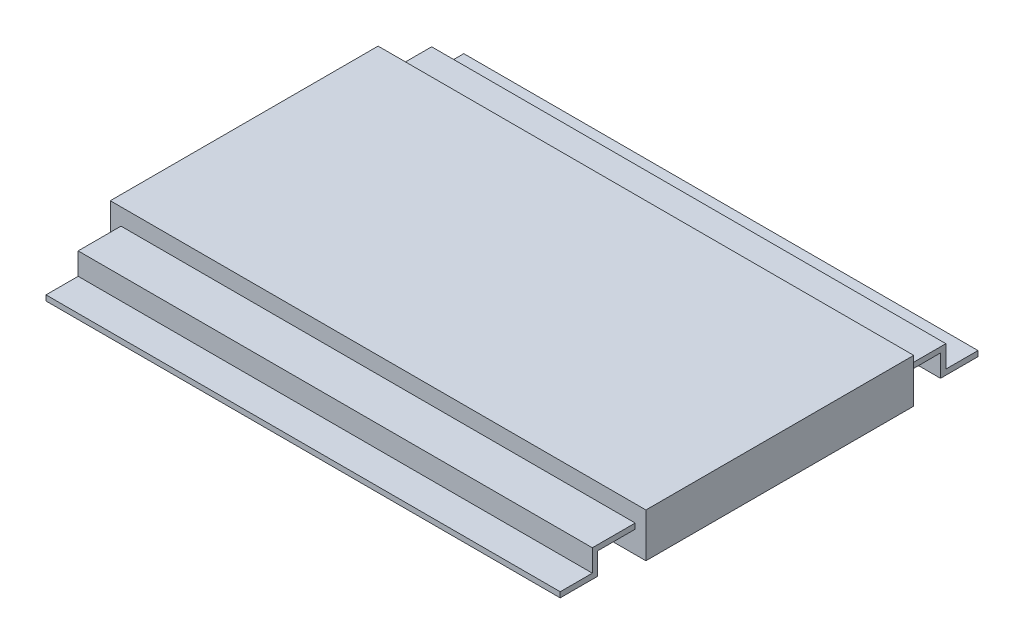
from build123d import *

# Parameters (mm, degrees)
SKETCH1_W           = 6.35
SKETCH1_H           = 1.044000004
BOSS_EXTRUDE1_DEPTH = 6.35
EXTRUDE_THIN1_DEPTH = 6.096


with BuildPart() as part:
    # Sketch1 → Boss-Extrude1 (new body, symmetric)
    with BuildSketch(Plane(origin=(0, 0, 0), x_dir=(0, 0, -1), z_dir=(1, 0, 0))):
        with Locations((0, 0.522000002)):
            Rectangle(SKETCH1_W, SKETCH1_H)
    extrude(amount=BOSS_EXTRUDE1_DEPTH, both=True)

    # Sketch2 → Extrude-Thin1 (add, symmetric)
    with BuildSketch(Plane(origin=(0, 0, 0), x_dir=(0, 0, -1), z_dir=(1, 0, 0))):
        Polygon((3.175, 0.522000002), (4.064, 0.522000002), (4.064, 0), (4.953, 0), (4.953, 0.127), (4.191, 0.127), (4.191, 0.649000002), (3.175, 0.649000002), align=None)
    extrude_thin1 = extrude(amount=EXTRUDE_THIN1_DEPTH, both=True)

    # Mirror1: Extrude-Thin1 across plane
    add(extrude_thin1.mirror(Plane.XY))


solid = part.part
